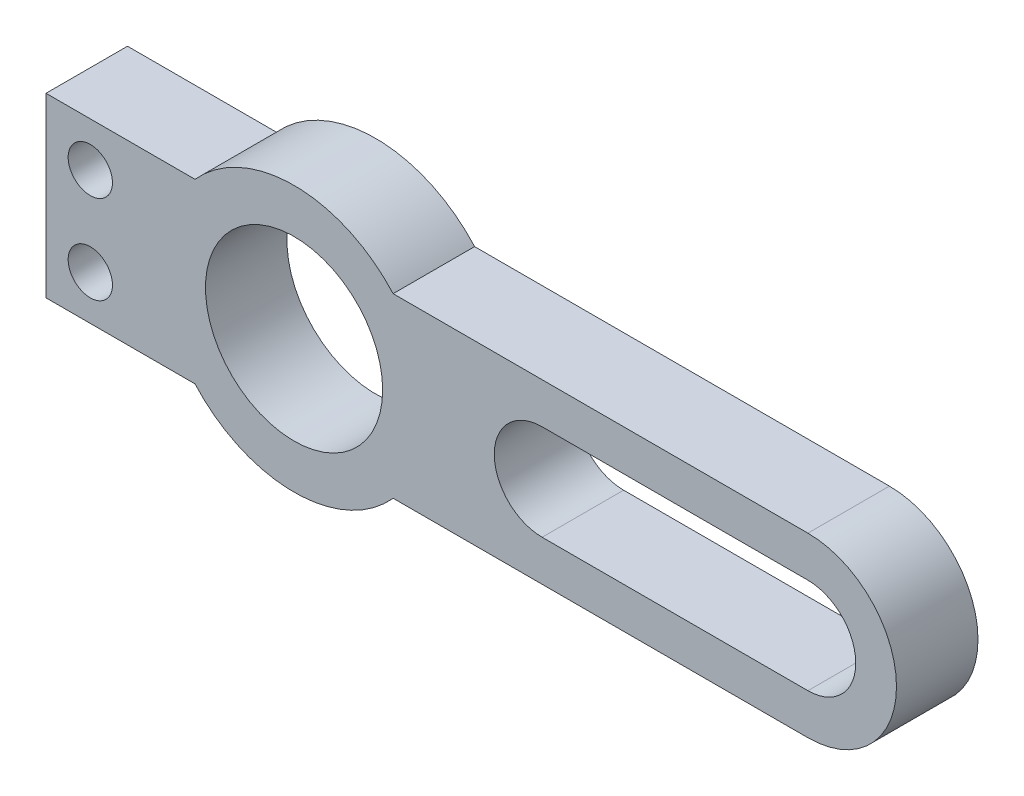
from build123d import *

# Parameters (mm, degrees)
SKETCH1_R           = 6.35
BOSS_EXTRUDE1_DEPTH = 6.35
SKETCH2_R           = 6.35
SKETCH2_R_2         = 3.175
BOSS_EXTRUDE2_DEPTH = 6.35
CUT_EXTRUDE1_REACH  = 37.549
CUT_EXTRUDE2_REACH  = 37.549
SKETCH5_R           = 1.5875
CUT_EXTRUDE3_DEPTH  = 36.548658906
MOVE_FACE1_BY       = 0.508
MOVE_FACE2_BY       = 0.254
MOVE_FACE2_2_BY     = 0.254
MOVE_FACE2_3_BY     = 0.254
MOVE_FACE2_4_BY     = 0.254


with BuildPart() as part:
    # Sketch1 → Boss-Extrude1 (new body)
    with BuildSketch(Plane.XY):
        with BuildLine():
            Line((-2.425484171, -6.35), (27.305, -6.35))
            Line((27.305, -6.35), (27.305, 6.35))
            Line((27.305, 6.35), (-2.425484171, 6.35))
            ThreePointArc((-2.425484171, 6.35), (-9.525, 9.525), (-16.624515829, 6.35))
            Line((-16.624515829, 6.35), (-27.305, 6.35))
            Line((-27.305, 6.35), (-27.305, -6.35))
            Line((-27.305, -6.35), (-16.624515829, -6.35))
            ThreePointArc((-16.624515829, -6.35), (-9.525, -9.525), (-2.425484171, -6.35))
        make_face()
        with Locations((-9.525, 0)):
            Circle(SKETCH1_R, mode=Mode.SUBTRACT)
    extrude(amount=BOSS_EXTRUDE1_DEPTH)

    # Sketch2 → Boss-Extrude2 (add)
    with BuildSketch(Plane.XY.offset(6.35)):
        with Locations((27.305, 0)):
            Circle(SKETCH2_R)
        with Locations((27.305, 0)):
            Circle(SKETCH2_R_2, mode=Mode.SUBTRACT)
    extrude(amount=-BOSS_EXTRUDE2_DEPTH)

    # Sketch3 → Cut-Extrude1 (cut, up to next)
    with BuildSketch(Plane.XY.offset(6.35), mode=Mode.PRIVATE) as cut_extrude1_sk1:
        with BuildLine():
            ThreePointArc((27.305, 3.175), (24.13, 0), (27.305, -3.175))
            Line((27.305, -3.175), (27.305, 3.175))
        make_face()
    cut_extrude1_tool1 = extrude(cut_extrude1_sk1.sketch, amount=-CUT_EXTRUDE1_REACH, mode=Mode.PRIVATE) & part.part
    add(cut_extrude1_tool1.solids().sort_by_distance((25.957488, 0, 6.35))[0], mode=Mode.SUBTRACT)

    # Sketch4 → Cut-Extrude2 (cut, up to next)
    with BuildSketch(Plane.XY.offset(6.35), mode=Mode.PRIVATE) as cut_extrude2_sk1:
        with BuildLine():
            Line((8.255, 3.175), (27.305, 3.175))
            ThreePointArc((27.305, 3.175), (30.48, 0), (27.305, -3.175))
            Line((27.305, -3.175), (8.255, -3.175))
            ThreePointArc((8.255, -3.175), (5.08, 0), (8.255, 3.175))
        make_face()
    cut_extrude2_tool1 = extrude(cut_extrude2_sk1.sketch, amount=-CUT_EXTRUDE2_REACH, mode=Mode.PRIVATE) & part.part
    add(cut_extrude2_tool1.solids().sort_by_distance((17.78, 0, 6.35))[0], mode=Mode.SUBTRACT)

    # Sketch5 → Cut-Extrude3 (cut, through all)
    with BuildSketch(Plane.XY.offset(6.35)):
        with Locations((-24.13, 3.175)):
            Circle(SKETCH5_R)
        with Locations((-24.13, -3.175)):
            Circle(SKETCH5_R)
    extrude(amount=-CUT_EXTRUDE3_DEPTH, mode=Mode.SUBTRACT)

    # Move Face1: a face moved inward by 0.508
    extrude(part.faces().sort_by_distance((0.343641582, 0, 6.35))[0], amount=MOVE_FACE1_BY, dir=(0, 0, -1), mode=Mode.SUBTRACT)

    # Move Face2: a curved face moved inward by 0.254
    add(Solid.thicken(part.faces().sort_by_distance((30.48, 0, 2.921))[0], -MOVE_FACE2_BY), mode=Mode.SUBTRACT)

    # Move Face2 2: a face moved inward by 0.254
    extrude(part.faces().sort_by_distance((17.78, 3.175, 2.921))[0], amount=MOVE_FACE2_2_BY, dir=(0, 1, 0), mode=Mode.SUBTRACT)

    # Move Face2 3: a curved face moved inward by 0.254
    add(Solid.thicken(part.faces().sort_by_distance((5.08, 0, 2.921))[0], -MOVE_FACE2_3_BY), mode=Mode.SUBTRACT)

    # Move Face2 4: a face moved inward by 0.254
    extrude(part.faces().sort_by_distance((17.78, -3.175, 2.921))[0], amount=MOVE_FACE2_4_BY, dir=(0, -1, 0), mode=Mode.SUBTRACT)


solid = part.part
